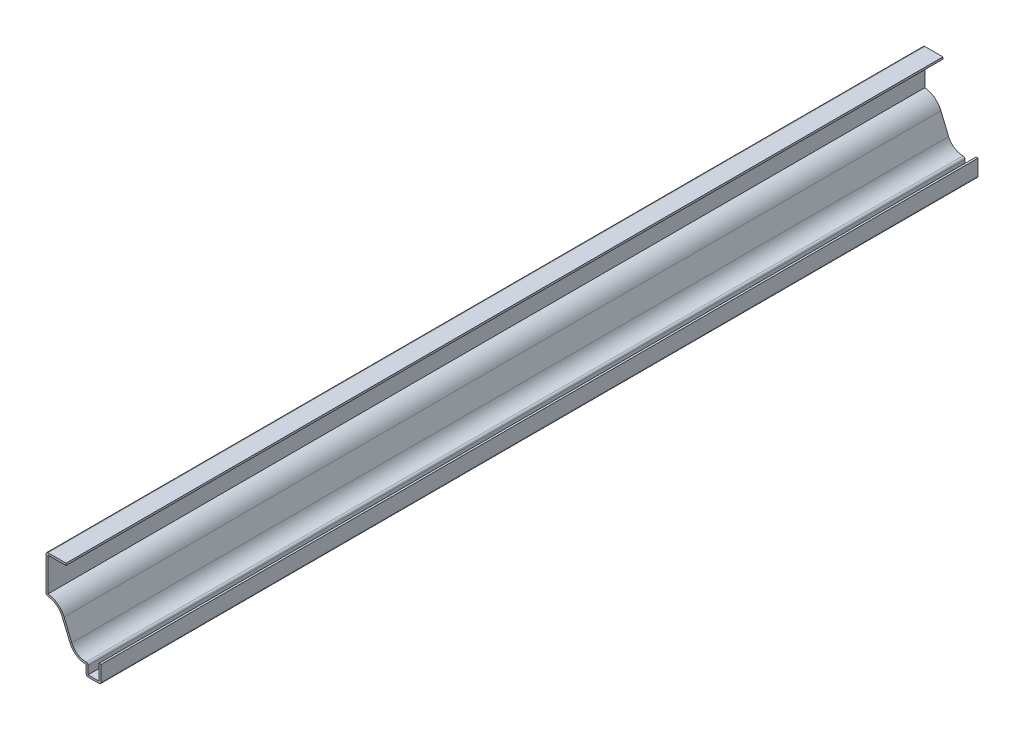
from build123d import *

# Parameters (mm, degrees)
EXTRUDE_THIN1_DEPTH = 555.625
FILLET1_R           = 1.27


with BuildPart() as part:
    # Sketch1 → Extrude-Thin1 (new body)
    with BuildSketch(Plane.XY):
        with BuildLine():
            Line((0, 0), (0, -11.1125))
            Line((0, -11.1125), (-9.525, -11.1125))
            Line((-9.525, -11.1125), (-9.525, -4.7625))
            ThreePointArc((-9.525, -4.7625), (-15.689105931, -2.896158896), (-19.782692308, 2.075961538))
            Line((-19.782692308, 2.075961538), (-24.667307692, 13.799038462))
            ThreePointArc((-24.667307692, 13.799038462), (-28.760894069, 18.771158896), (-34.925, 20.6375))
            Line((-34.925, 20.6375), (-34.925, 44.45))
            Line((-34.925, 44.45), (-22.225, 44.45))
            Line((-22.225, 44.45), (-22.225, 43.18))
            Line((-22.225, 43.18), (-33.655, 43.18))
            Line((-33.655, 43.18), (-33.655, 21.842199611))
            ThreePointArc((-33.655, 21.842199611), (-27.536436435, 19.46157057), (-23.495, 14.2875))
            Line((-23.495, 14.2875), (-18.610384615, 2.564423077))
            ThreePointArc((-18.610384615, 2.564423077), (-14.443755021, -2.175295027), (-8.255, -3.410220605))
            Line((-8.255, -3.410220605), (-8.255, -9.8425))
            Line((-8.255, -9.8425), (-1.27, -9.8425))
            Line((-1.27, -9.8425), (-1.27, 0))
            Line((-1.27, 0), (0, 0))
        make_face()
    extrude(amount=-EXTRUDE_THIN1_DEPTH)

    # Fillet1
    fillet1_edges = [part.edges().sort_by_distance(p)[0] for p in [
        (-8.255, -3.410220605, -277.8125),
        (0, -11.1125, -277.8125),
        (-9.525, -11.1125, -277.8125),
        (-34.925, 20.6375, -277.8125),
        (-34.925, 44.45, -277.8125),
    ]]
    fillet(fillet1_edges, radius=FILLET1_R)


solid = part.part
